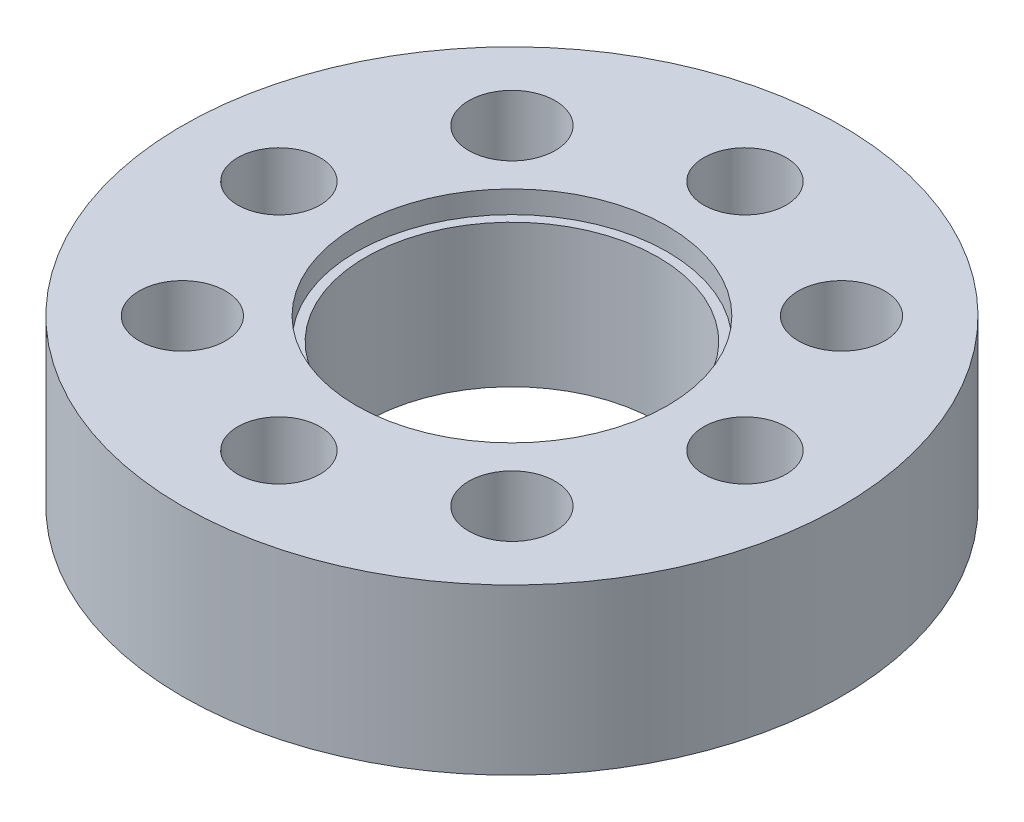
from build123d import *

# Parameters (mm, degrees)
SKETCH1_R           = 16
SKETCH1_R_2         = 7.1
SKETCH1_R_3         = 2
SKETCH1_R_4         = 2.1
BOSS_EXTRUDE1_DEPTH = 8
SKETCH2_R           = 7.55
CUT_EXTRUDE1_DEPTH  = 1.08


with BuildPart() as part:
    # Sketch1 → Boss-Extrude1 (new body)
    with BuildSketch(Plane(origin=(0, 0, 0), x_dir=(1, 0, 0), z_dir=(0, 1, 0))):
        Circle(SKETCH1_R)
        Circle(SKETCH1_R_2, mode=Mode.SUBTRACT)
        with Locations((0, 11.313708499)):
            Circle(SKETCH1_R_3, mode=Mode.SUBTRACT)
        with Locations((-11.313708499, 0)):
            Circle(SKETCH1_R_3, mode=Mode.SUBTRACT)
        with Locations((0, -11.313708499)):
            Circle(SKETCH1_R_3, mode=Mode.SUBTRACT)
        with Locations((11.313708499, 0)):
            Circle(SKETCH1_R_3, mode=Mode.SUBTRACT)
        with Locations((-8, -8)):
            Circle(SKETCH1_R_4, mode=Mode.SUBTRACT)
        with Locations((8, -8)):
            Circle(SKETCH1_R_4, mode=Mode.SUBTRACT)
        with Locations((8, 8)):
            Circle(SKETCH1_R_4, mode=Mode.SUBTRACT)
        with Locations((-8, 8)):
            Circle(SKETCH1_R_4, mode=Mode.SUBTRACT)
    extrude(amount=BOSS_EXTRUDE1_DEPTH)

    # Sketch2 → Cut-Extrude1 (cut)
    with BuildSketch(Plane(origin=(0, 8, 0), x_dir=(1, 0, 0), z_dir=(0, 1, 0))):
        Circle(SKETCH2_R)
    extrude(amount=-CUT_EXTRUDE1_DEPTH, mode=Mode.SUBTRACT)


solid = part.part
